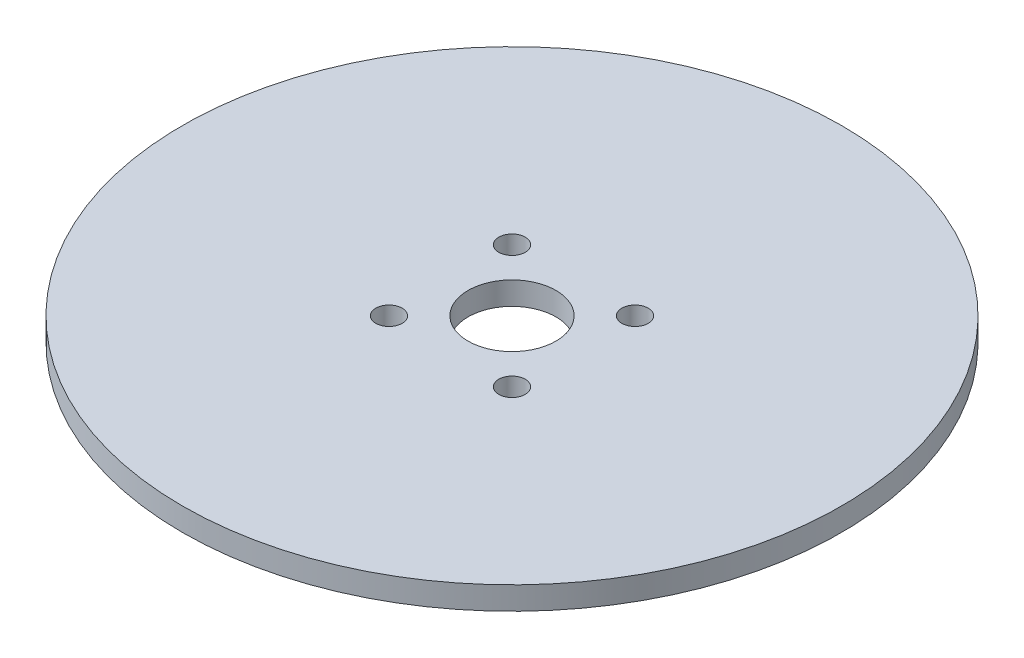
from build123d import *

# Parameters (mm, degrees)
SKETCH1_R           = 37.5
BOSS_EXTRUDE1_DEPTH = 2.61
SKETCH2_R           = 5
CUT_EXTRUDE1_DEPTH  = 13.05
SKETCH3_R           = 1.5
CUT_EXTRUDE2_DEPTH  = 3.61


with BuildPart() as part:
    # Sketch1 → Boss-Extrude1 (new body)
    with BuildSketch(Plane(origin=(0, 0, 0), x_dir=(1, 0, 0), z_dir=(0, 1, 0))):
        Circle(SKETCH1_R)
    extrude(amount=BOSS_EXTRUDE1_DEPTH)

    # Sketch2 → Cut-Extrude1 (cut)
    with BuildSketch(Plane(origin=(0, 2.61, 0), x_dir=(1, 0, 0), z_dir=(0, 1, 0))):
        Circle(SKETCH2_R)
    extrude(amount=-CUT_EXTRUDE1_DEPTH, mode=Mode.SUBTRACT)

    # Sketch3 → Cut-Extrude2 (cut, through all)
    with BuildSketch(Plane(origin=(0, 2.61, 0), x_dir=(1, 0, 0), z_dir=(0, 1, 0))):
        with Locations((-7, 7)):
            Circle(SKETCH3_R)
        with Locations((7, 7)):
            Circle(SKETCH3_R)
        with Locations((7, -7)):
            Circle(SKETCH3_R)
        with Locations((-7, -7)):
            Circle(SKETCH3_R)
    extrude(amount=-CUT_EXTRUDE2_DEPTH, mode=Mode.SUBTRACT)


solid = part.part
